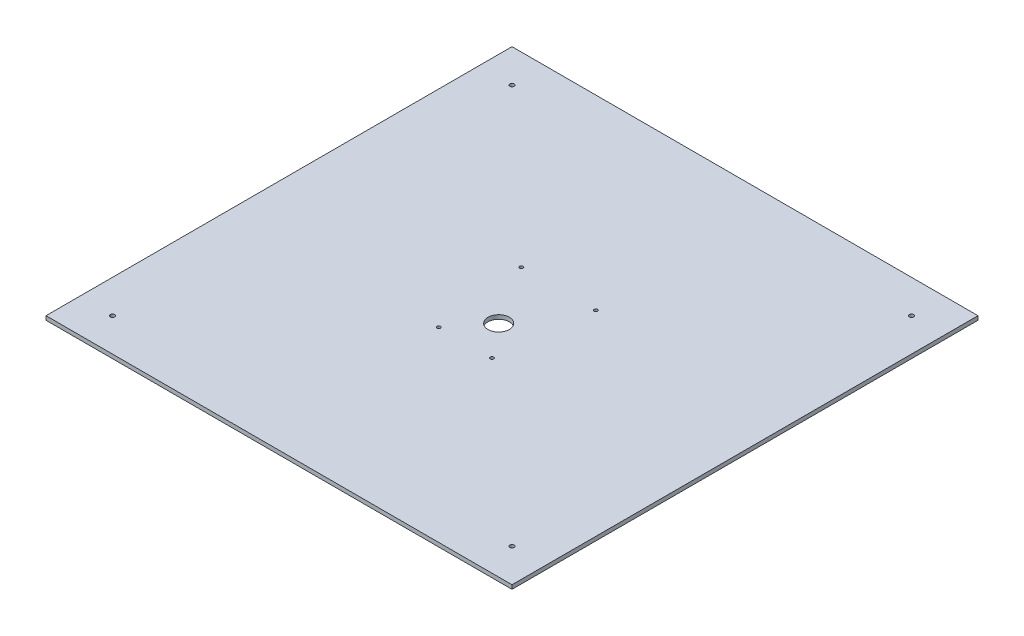
from build123d import *

# Parameters (mm, degrees)
SKETCH1_W           = 350.000000098
SKETCH1_H           = 350.000000098
SKETCH1_R           = 1.6
BOSS_EXTRUDE1_DEPTH = 3
SKETCH2_R           = 8
SKETCH2_R_2         = 1.3
CUT_EXTRUDE1_DEPTH  = 3


with BuildPart() as part:
    # Sketch1 → Boss-Extrude1 (new body)
    with BuildSketch(Plane(origin=(0, 0, 0), x_dir=(1, 0, 0), z_dir=(0, 1, 0))):
        Rectangle(SKETCH1_W, SKETCH1_H)
        with Locations((-150, 150)):
            Circle(SKETCH1_R, mode=Mode.SUBTRACT)
        with Locations((-150, -150)):
            Circle(SKETCH1_R, mode=Mode.SUBTRACT)
        with Locations((150, -150)):
            Circle(SKETCH1_R, mode=Mode.SUBTRACT)
        with Locations((150, 150)):
            Circle(SKETCH1_R, mode=Mode.SUBTRACT)
    extrude(amount=BOSS_EXTRUDE1_DEPTH)

    # Sketch2 → Cut-Extrude1 (cut)
    with BuildSketch(Plane(origin=(0, 3, 0), x_dir=(1, 0, 0), z_dir=(0, 1, 0))):
        with Locations((0, -10)):
            Circle(SKETCH2_R)
        with Locations((-28, 35)):
            Circle(SKETCH2_R_2)
        with Locations((28, 35)):
            Circle(SKETCH2_R_2)
        with Locations((-20, -35)):
            Circle(SKETCH2_R_2)
        with Locations((20, -35)):
            Circle(SKETCH2_R_2)
    extrude(amount=-CUT_EXTRUDE1_DEPTH, mode=Mode.SUBTRACT)


solid = part.part
